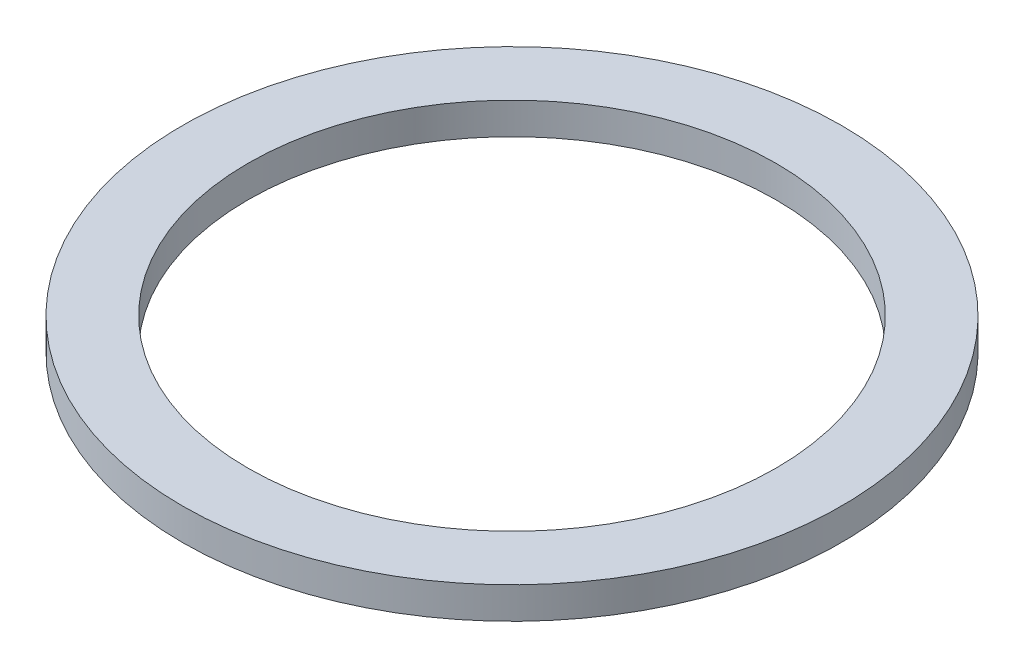
from build123d import *

# Parameters (mm, degrees)
SKETCH2_R           = 49.55
SKETCH2_R_2         = 39.7
BOSS_EXTRUDE1_DEPTH = 4.7625


with BuildPart() as part:
    # Sketch2 → Boss-Extrude1 (new body)
    with BuildSketch(Plane(origin=(0, 0, 0), x_dir=(1, 0, 0), z_dir=(0, 1, 0))):
        Circle(SKETCH2_R)
        Circle(SKETCH2_R_2, mode=Mode.SUBTRACT)
    extrude(amount=BOSS_EXTRUDE1_DEPTH)


solid = part.part
